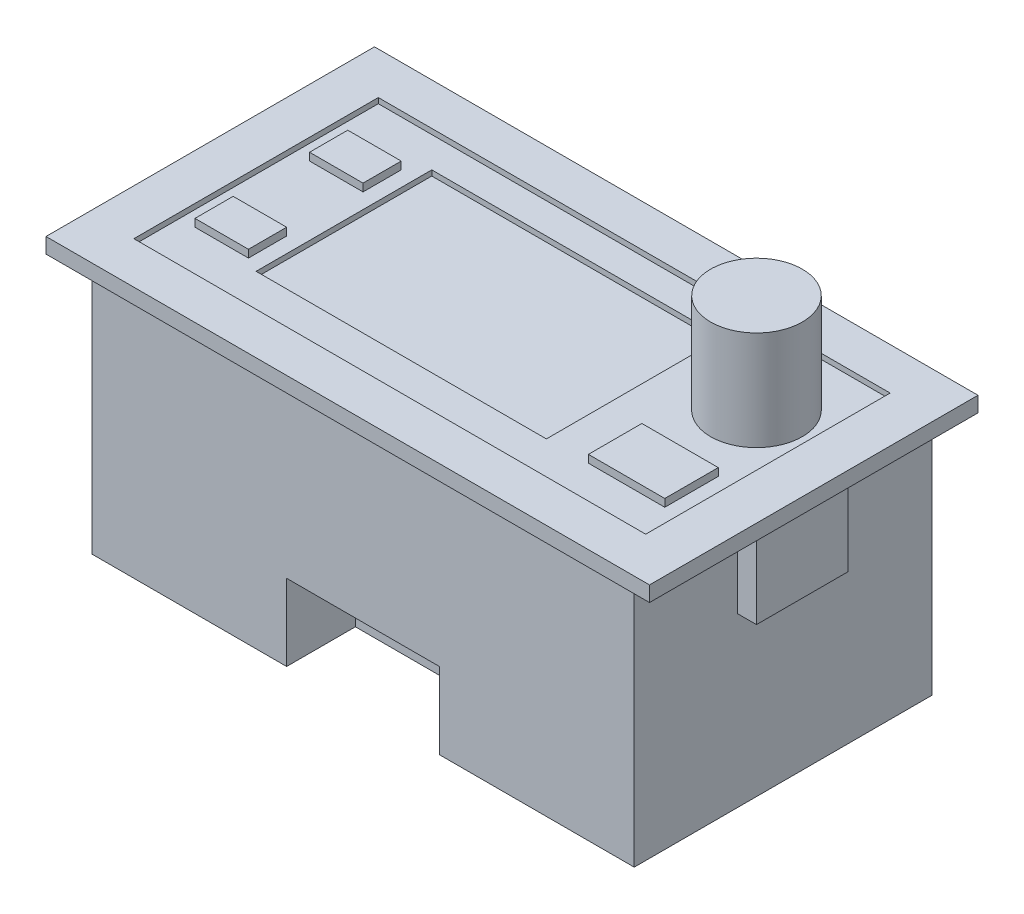
from build123d import *

# Parameters (mm, degrees)
SKETCH2_W           = 79
SKETCH2_H           = 43
BOSS_EXTRUDE1_DEPTH = 2
SKETCH3_W           = 67
SKETCH3_H           = 32
CUT_EXTRUDE1_DEPTH  = 0.7
SKETCH4_W           = 38
SKETCH4_H           = 23
CUT_EXTRUDE2_DEPTH  = 0.7
SKETCH7_R           = 6
BOSS_EXTRUDE2_DEPTH = 13
SKETCH8_W           = 10
SKETCH8_H           = 7
BOSS_EXTRUDE3_DEPTH = 1
SKETCH9_W           = 7
SKETCH9_H           = 5
BOSS_EXTRUDE4_DEPTH = 1
SKETCH10_W          = 71
SKETCH10_H          = 39
BOSS_EXTRUDE5_DEPTH = 33
SKETCH11_W          = 20
SKETCH11_H          = 18
CUT_EXTRUDE3_DEPTH  = 10
BOSS_EXTRUDE6_DEPTH = 2.5
BOSS_EXTRUDE7_DEPTH = 2.5


with BuildPart() as part:
    # Sketch2 → Boss-Extrude1 (new body)
    with BuildSketch(Plane(origin=(0, 0, 0), x_dir=(1, 0, 0), z_dir=(0, 1, 0))):
        with Locations((39.5, 21.5)):
            Rectangle(SKETCH2_W, SKETCH2_H)
    extrude(amount=BOSS_EXTRUDE1_DEPTH)

    # Sketch3 → Cut-Extrude1 (cut)
    with BuildSketch(Plane(origin=(0, 2, 0), x_dir=(1, 0, 0), z_dir=(0, 1, 0))):
        with Locations((39.5, 21.5)):
            Rectangle(SKETCH3_W, SKETCH3_H)
    extrude(amount=-CUT_EXTRUDE1_DEPTH, mode=Mode.SUBTRACT)

    # Sketch4 → Cut-Extrude2 (cut)
    with BuildSketch(Plane(origin=(0, 1.3, 0), x_dir=(1, 0, 0), z_dir=(0, 1, 0))):
        with Locations((36, 22)):
            Rectangle(SKETCH4_W, SKETCH4_H)
    extrude(amount=-CUT_EXTRUDE2_DEPTH, mode=Mode.SUBTRACT)

    # Sketch7 → Boss-Extrude2 (add)
    with BuildSketch(Plane(origin=(0, 1.3, 0), x_dir=(1, 0, 0), z_dir=(0, 1, 0))):
        with Locations((65.5, 27.5)):
            Circle(SKETCH7_R)
    extrude(amount=BOSS_EXTRUDE2_DEPTH)

    # Sketch8 → Boss-Extrude3 (add)
    with BuildSketch(Plane(origin=(0, 1.3, 0), x_dir=(1, 0, 0), z_dir=(0, 1, 0))):
        with Locations((65.5, 14)):
            Rectangle(SKETCH8_W, SKETCH8_H)
    extrude(amount=BOSS_EXTRUDE3_DEPTH)

    # Sketch9 → Boss-Extrude4 (add)
    with BuildSketch(Plane(origin=(0, 1.3, 0), x_dir=(1, 0, 0), z_dir=(0, 1, 0))):
        with Locations((11.5, 14)):
            Rectangle(SKETCH9_W, SKETCH9_H)
        with Locations((11.5, 29)):
            Rectangle(SKETCH9_W, SKETCH9_H)
    extrude(amount=BOSS_EXTRUDE4_DEPTH)

    # Sketch10 → Boss-Extrude5 (add)
    with BuildSketch(Plane.XZ):
        with Locations((39.5, -21.5)):
            Rectangle(SKETCH10_W, SKETCH10_H)
    extrude(amount=BOSS_EXTRUDE5_DEPTH)

    # Sketch11 → Cut-Extrude3 (cut)
    with BuildSketch(Plane(origin=(0, -33, 0), x_dir=(-1, 0, 0), z_dir=(0, -1, 0))):
        with Locations((-39.5, 2)):
            Rectangle(SKETCH11_W, SKETCH11_H)
    extrude(amount=-CUT_EXTRUDE3_DEPTH, mode=Mode.SUBTRACT)

    # Sketch12 → Boss-Extrude6 (add)
    with BuildSketch(Plane.ZY.offset(-4)):
        Polygon((-21.5, 0), (-27.5, 0), (-27.5, -11), (-21.5, -11), (-15.5, -11), (-15.5, 0), align=None)
    extrude(amount=BOSS_EXTRUDE6_DEPTH)

    # Sketch13 → Boss-Extrude7 (add)
    with BuildSketch(Plane(origin=(75, 0, 0), x_dir=(0, 0, -1), z_dir=(1, 0, 0))):
        Polygon((21.5, 0), (15.5, 0), (15.5, -11), (21.5, -11), (27.5, -11), (27.5, 0), align=None)
    extrude(amount=BOSS_EXTRUDE7_DEPTH)


solid = part.part
